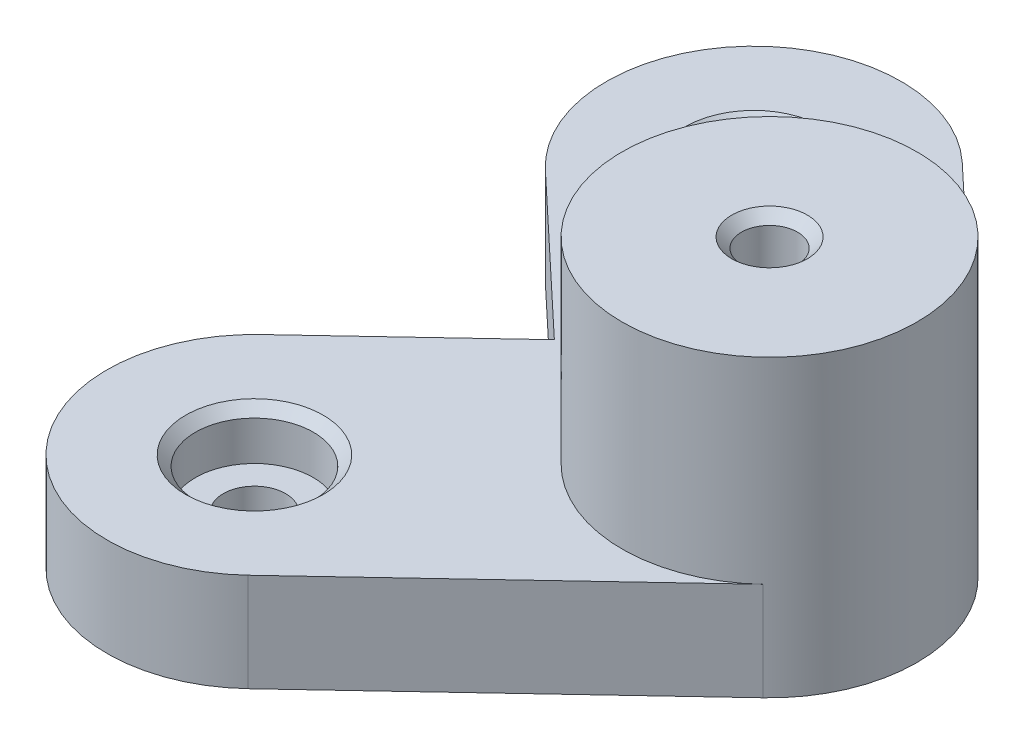
from build123d import *

# Parameters (mm, degrees)
SKETCH4_R           = 3.175
BOSS_EXTRUDE1_DEPTH = 10
SKETCH5_R           = 15
BOSS_EXTRUDE2_DEPTH = 20
SKETCH6_R           = 2.85
CUT_EXTRUDE1_DEPTH  = 38
SKETCH7_R           = 6
CUT_EXTRUDE2_DEPTH  = 5
SKETCH8_R           = 6
CUT_EXTRUDE3_DEPTH  = 5
CHAMFER1_SIZE       = 1


with BuildPart() as part:
    # Sketch4 → Boss-Extrude1 (new body)
    with BuildSketch(Plane(origin=(0, 0, 0), x_dir=(1, 0, 0), z_dir=(0, 1, 0))):
        with BuildLine():
            Line((-89.722054171, 10.925375487), (-116.722054171, 36.325375487))
            ThreePointArc((-116.722054171, 36.325375487), (-137.925375487, 35.677945829), (-137.277945829, 14.474624513))
            Line((-137.277945829, 14.474624513), (-121.891533945, 0))
            Line((-121.891533945, 0), (-137.277945829, -14.474624513))
            ThreePointArc((-137.277945829, -14.474624513), (-137.925375487, -35.677945829), (-116.722054171, -36.325375487))
            Line((-116.722054171, -36.325375487), (-89.722054171, -10.925375487))
            ThreePointArc((-89.722054171, -10.925375487), (-85, 0), (-89.722054171, 10.925375487))
        make_face()
        with Locations((-127, 25.4)):
            Circle(SKETCH4_R, mode=Mode.SUBTRACT)
        with Locations((-127, -25.4)):
            Circle(SKETCH4_R, mode=Mode.SUBTRACT)
    extrude(amount=BOSS_EXTRUDE1_DEPTH)

    # Sketch5 → Boss-Extrude2 (add)
    with BuildSketch(Plane(origin=(0, 10, 0), x_dir=(1, 0, 0), z_dir=(0, 1, 0))):
        with Locations((-100, 0)):
            Circle(SKETCH5_R)
    extrude(amount=BOSS_EXTRUDE2_DEPTH)

    # Sketch6 → Cut-Extrude1 (cut)
    with BuildSketch(Plane(origin=(0, 30, 0), x_dir=(1, 0, 0), z_dir=(0, 1, 0))):
        with Locations((-100, 0)):
            Circle(SKETCH6_R)
    extrude(amount=-CUT_EXTRUDE1_DEPTH, mode=Mode.SUBTRACT)

    # Sketch7 → Cut-Extrude2 (cut)
    with BuildSketch(Plane(origin=(0, 10, 0), x_dir=(1, 0, 0), z_dir=(0, 1, 0))):
        with Locations((-127, -25.4)):
            Circle(SKETCH7_R)
    extrude(amount=-CUT_EXTRUDE2_DEPTH, mode=Mode.SUBTRACT)

    # Sketch8 → Cut-Extrude3 (cut)
    with BuildSketch(Plane(origin=(0, 10, 0), x_dir=(1, 0, 0), z_dir=(0, 1, 0))):
        with Locations((-127, 25.4)):
            Circle(SKETCH8_R)
    extrude(amount=-CUT_EXTRUDE3_DEPTH, mode=Mode.SUBTRACT)

    # Chamfer1
    chamfer1_edges = [part.edges().sort_by_distance(p)[0] for p in [
        (-102.85, 30, 0),
        (-133, 10, 25.4),
        (-133, 10, -25.4),
    ]]
    chamfer(chamfer1_edges, length=CHAMFER1_SIZE)


solid = part.part
